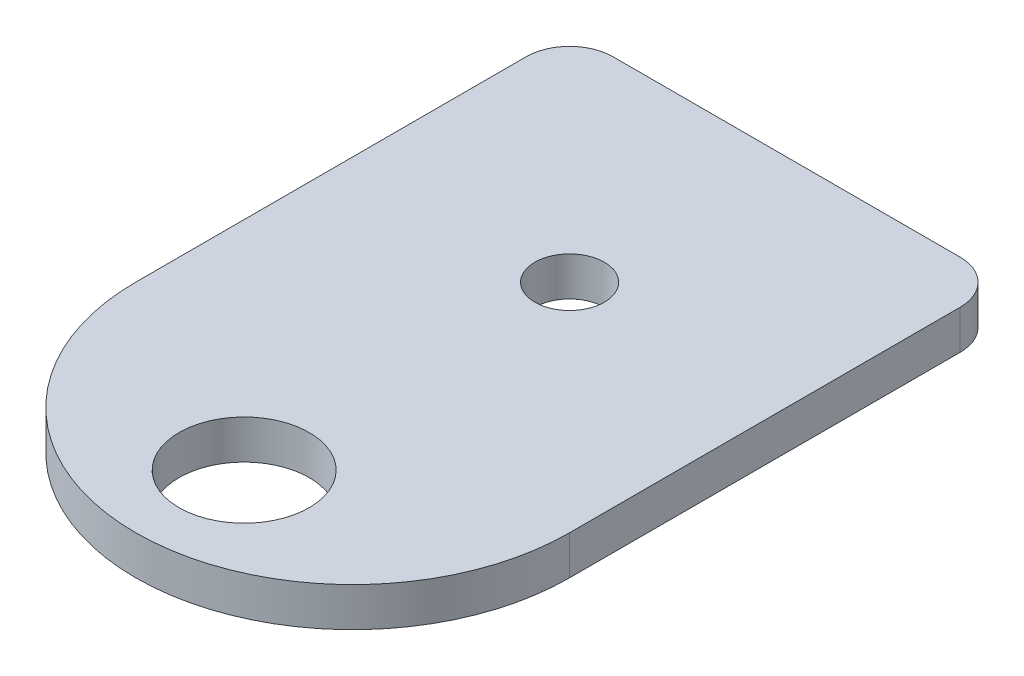
from build123d import *

# Parameters (mm, degrees)
BOSS_EXTRUDE1_DEPTH     = 2.286
SKETCH2_R               = 2.032
SKETCH2_R_2             = 3.81
CUT_EXTRUDE1_DEPTH      = 1
CUT_EXTRUDE1_DEPTH_BACK = 3.286
FILLET1_R               = 2.54
FILLET2_R               = 2.54


with BuildPart() as part:
    # Sketch1 → Boss-Extrude1 (new body)
    with BuildSketch(Plane(origin=(0, 0, 0), x_dir=(1, 0, 0), z_dir=(0, 1, 0))):
        with BuildLine():
            ThreePointArc((25.4, -25.4), (12.7, -12.7), (0, -25.4))
            Line((0, -25.4), (25.4, -25.4))
        make_face()
        with BuildLine():
            Line((25.4, -25.4), (0, -25.4))
            ThreePointArc((0, -25.4), (12.7, -38.1), (25.4, -25.4))
        make_face()
        with BuildLine():
            Line((25.4, 0), (0, 0))
            Line((0, 0), (0, -25.4))
            ThreePointArc((0, -25.4), (12.7, -12.7), (25.4, -25.4))
            Line((25.4, -25.4), (25.4, 0))
        make_face()
    extrude(amount=BOSS_EXTRUDE1_DEPTH)

    # Sketch2 → Cut-Extrude1 (cut, two sides)
    with BuildSketch(Plane(origin=(0, 2.286, 0), x_dir=(1, 0, 0), z_dir=(0, 1, 0))) as cut_extrude1_sk:
        with Locations((12.7, -12.7)):
            Circle(SKETCH2_R)
        with Locations((12.7, -31.75)):
            Circle(SKETCH2_R_2)
    extrude(amount=CUT_EXTRUDE1_DEPTH, mode=Mode.SUBTRACT)
    extrude(cut_extrude1_sk.sketch, amount=-CUT_EXTRUDE1_DEPTH_BACK, mode=Mode.SUBTRACT)

    # Fillet1
    fillet1_edges = [part.edges().sort_by_distance(p)[0] for p in [
        (0, 1.143, 0),
    ]]
    fillet(fillet1_edges, radius=FILLET1_R)

    # Fillet2
    fillet2_edges = [part.edges().sort_by_distance(p)[0] for p in [
        (25.4, 1.143, 0),
    ]]
    fillet(fillet2_edges, radius=FILLET2_R)


solid = part.part
